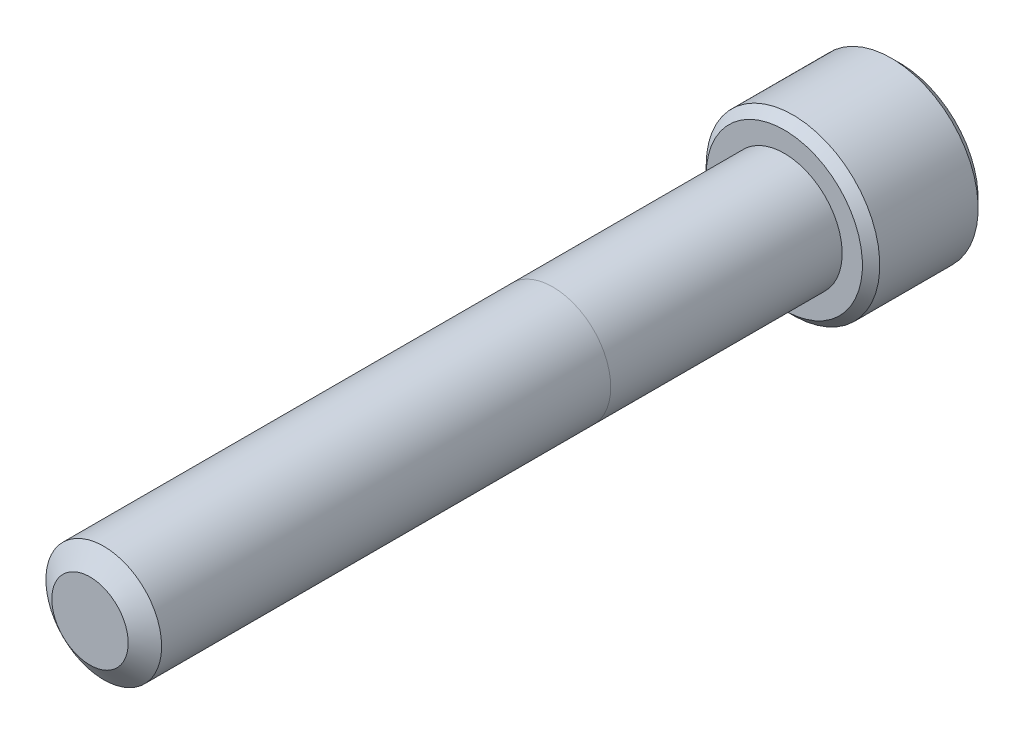
from build123d import *

# Parameters (mm, degrees)
SKETCH1_R          = 3.175
EXTRUDE1_DEPTH     = 38.1
SKETCH6_R          = 4.7625
EXTRUDE2_DEPTH     = 6.35
CUT_EXTRUDE1_DEPTH = 3.571875
CHAMFER1_SIZE      = 0.47625


with BuildPart() as part:
    # Sketch1 → Extrude1 (new body)
    with BuildSketch(Plane.XY):
        Circle(SKETCH1_R)
    extrude(amount=-EXTRUDE1_DEPTH)

    # Sketch4 → Cut-Revolve1 (revolve, cut)
    with BuildSketch(Plane(origin=(0, 0, 0), x_dir=(0, 0, -1), z_dir=(1, 0, 0))):
        Polygon((0.755446349, 3.175), (0, 2.096110803), (0, 3.175), align=None)
    revolve(axis=Axis((0, 0, 0), (0, 0, -1)), mode=Mode.SUBTRACT)

    # Sketch6 → Extrude2 (add)
    with BuildSketch(Plane(origin=(0, 0, -38.1), x_dir=(-1, 0, 0), z_dir=(0, 0, -1))):
        Circle(SKETCH6_R)
    extrude(amount=EXTRUDE2_DEPTH)

    # Sketch7 → Cut-Extrude1 (cut)
    with BuildSketch(Plane(origin=(0, 0, -44.45), x_dir=(-1, 0, 0), z_dir=(0, 0, -1))):
        Polygon((0, 2.749630657), (-2.38125, 1.374815329), (-2.38125, -1.374815329), (0, -2.749630657), (2.38125, -1.374815329), (2.38125, 1.374815329), align=None)
    extrude(amount=-CUT_EXTRUDE1_DEPTH, mode=Mode.SUBTRACT)

    # Cut-Extrude2 cone 1 section (through the dimple's axis) → Cut-Extrude2 (revolve, cut)
    with BuildSketch(Plane(origin=(0, 0, -44.45), x_dir=(0, 1, 0), z_dir=(1, 0, 0))):
        Polygon((0, 0), (2.749630657, 0), (0, 2.749630657), align=None)
    revolve(axis=Axis((0, 0, -44.45), (0, 0, 1)), mode=Mode.SUBTRACT)

    # Chamfer1
    chamfer1_edges = [part.edges().sort_by_distance(p)[0] for p in [
        (4.7625, 0, -44.45),
        (4.7625, 0, -38.1),
    ]]
    chamfer(chamfer1_edges, length=CHAMFER1_SIZE)


solid = part.part
